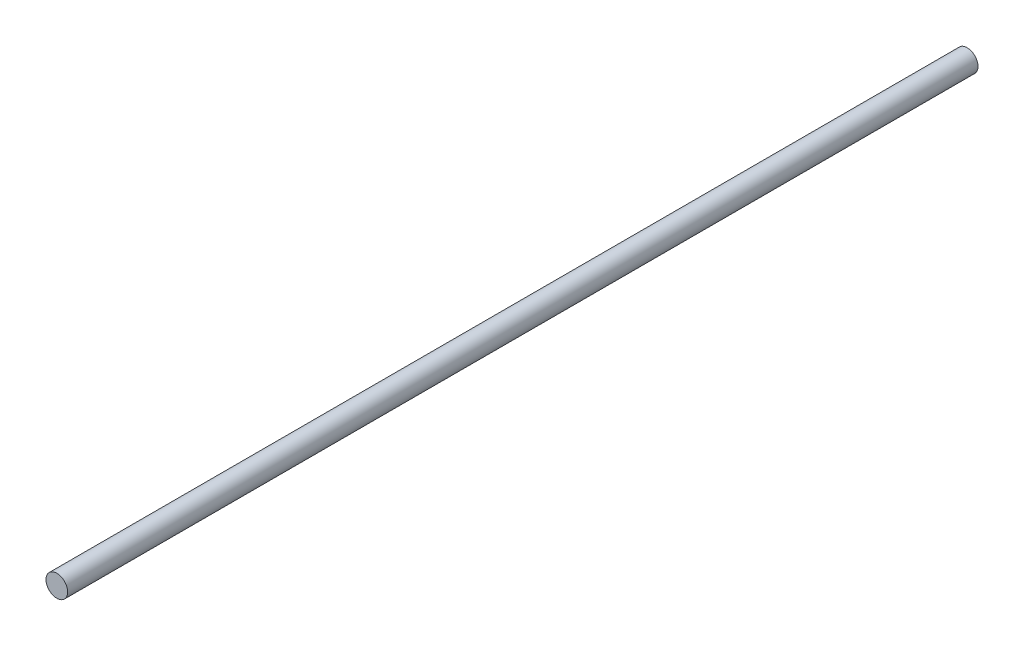
from build123d import *

# Parameters (mm, degrees)
SKETCH1_R           = 5
BOSS_EXTRUDE1_DEPTH = 420


with BuildPart() as part:
    # Sketch1 → Boss-Extrude1 (new body)
    with BuildSketch(Plane.XY):
        Circle(SKETCH1_R)
    extrude(amount=BOSS_EXTRUDE1_DEPTH)


solid = part.part
